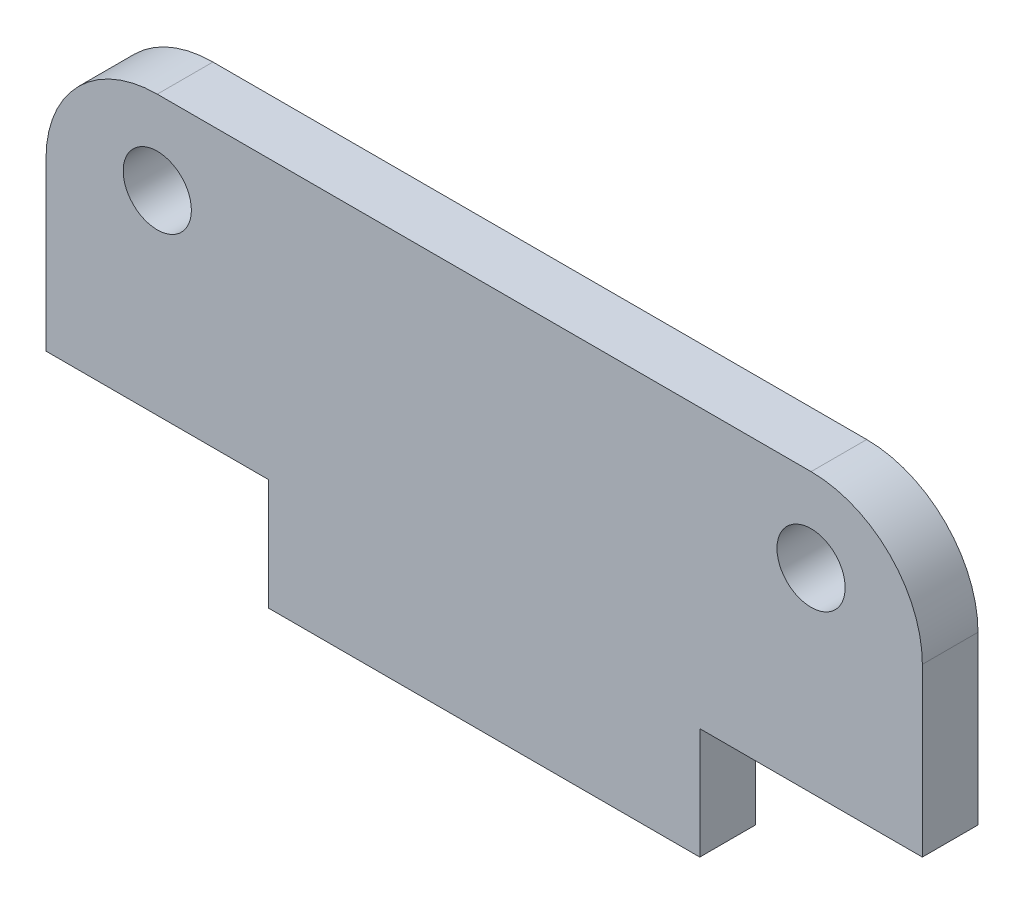
from build123d import *

# Parameters (mm, degrees)
SKETCH1_R       = 1.225
MAIN_BODY_DEPTH = 2


with BuildPart() as part:
    # Sketch1 → Main Body (new body)
    with BuildSketch(Plane.XY):
        with BuildLine():
            Line((-15.75, -7), (-7.75, -7))
            Line((-7.75, -7), (-7.75, -11))
            Line((-7.75, -11), (7.75, -11))
            Line((7.75, -11), (7.75, -7))
            Line((7.75, -7), (15.75, -7))
            Line((15.75, -7), (15.75, -1))
            ThreePointArc((15.75, -1), (14.578427125, 1.828427125), (11.75, 3))
            Line((11.75, 3), (-11.75, 3))
            ThreePointArc((-11.75, 3), (-14.578427125, 1.828427125), (-15.75, -1))
            Line((-15.75, -1), (-15.75, -7))
        make_face()
        with Locations((-11.75, 0)):
            Circle(SKETCH1_R, mode=Mode.SUBTRACT)
        with Locations((11.75, 0)):
            Circle(SKETCH1_R, mode=Mode.SUBTRACT)
    extrude(amount=MAIN_BODY_DEPTH)


solid = part.part
